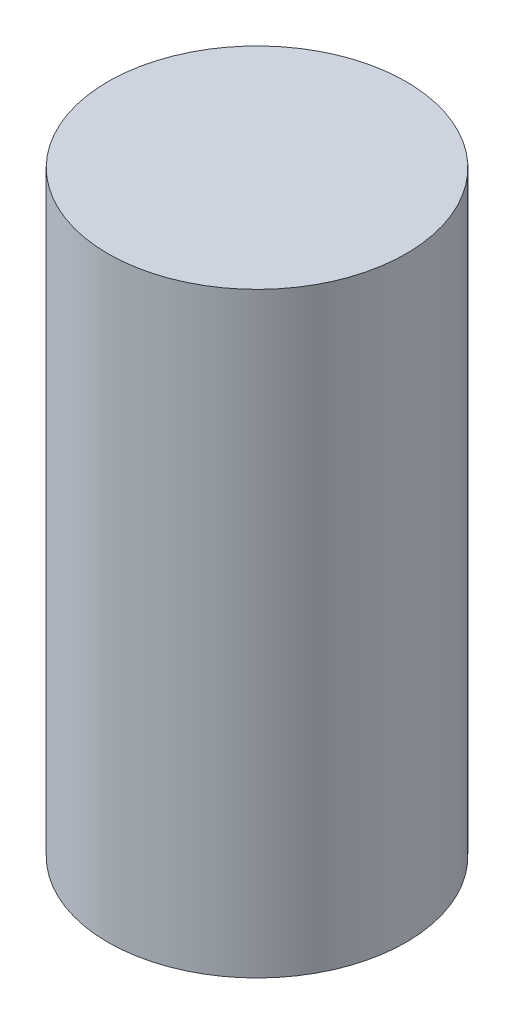
from build123d import *

# Parameters (mm, degrees)
SKETCH1_R           = 50.8
BOSS_EXTRUDE1_DEPTH = 203.2


with BuildPart() as part:
    # Sketch1 → Boss-Extrude1 (new body)
    with BuildSketch(Plane(origin=(0, 0, 0), x_dir=(1, 0, 0), z_dir=(0, 1, 0))):
        Circle(SKETCH1_R)
    extrude(amount=BOSS_EXTRUDE1_DEPTH)


solid = part.part
